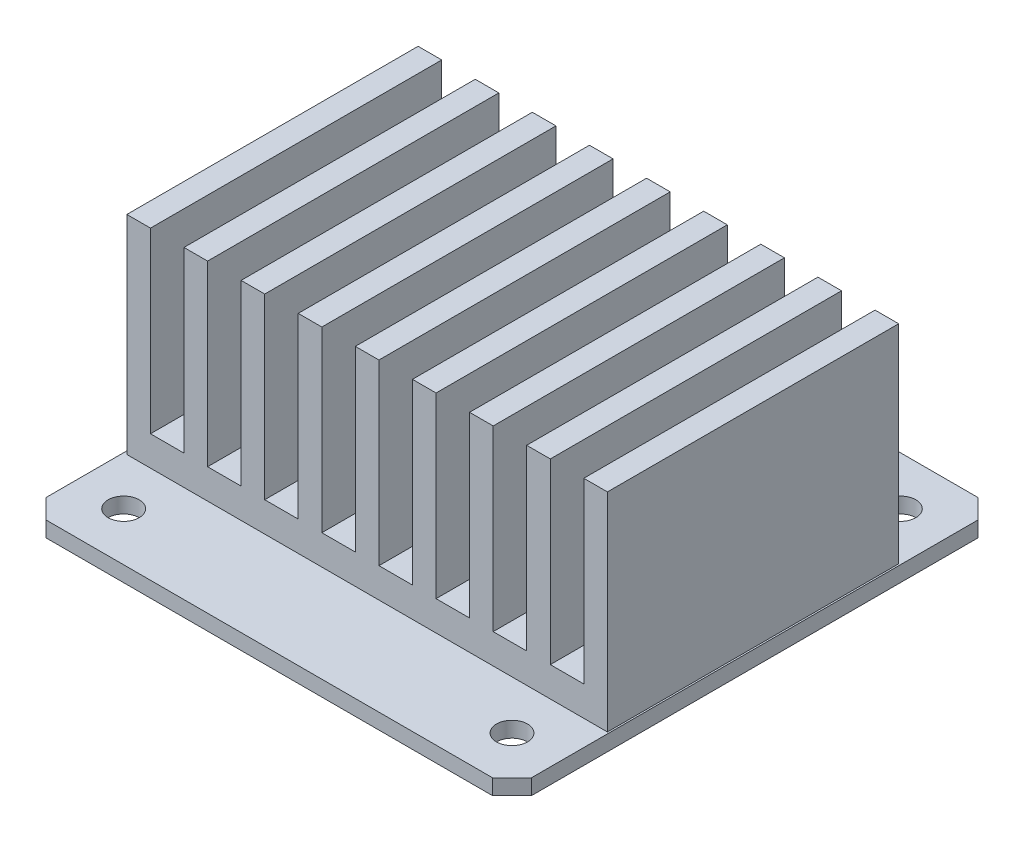
from build123d import *

# Parameters (mm, degrees)
SKETCH1_R                = 1.6
BOSS_EXTRUDE1_DEPTH      = 1.6
BOSS_EXTRUDE2_DEPTH      = 15
BOSS_EXTRUDE2_DEPTH_BACK = 15
SKETCH3_R                = 4.484115481
BOSS_EXTRUDE3_DEPTH      = 15
SKETCH4_W                = 17.802607731
SKETCH4_H                = 6.826563867
BOSS_EXTRUDE4_DEPTH      = 10


with BuildPart() as part:
    # Sketch1 → Boss-Extrude1 (new body)
    with BuildSketch(Plane(origin=(0, 0, 0), x_dir=(1, 0, 0), z_dir=(0, 1, 0))):
        Polygon((-25, 23), (-23, 25), (23, 25), (25, 23), (25, -23), (23, -25), (-23, -25), (-25, -23), align=None)
        with Locations((20, 20)):
            Circle(SKETCH1_R, mode=Mode.SUBTRACT)
        with Locations((-20, 20)):
            Circle(SKETCH1_R, mode=Mode.SUBTRACT)
        with Locations((-20, -20)):
            Circle(SKETCH1_R, mode=Mode.SUBTRACT)
        with Locations((20, -20)):
            Circle(SKETCH1_R, mode=Mode.SUBTRACT)
    extrude(amount=BOSS_EXTRUDE1_DEPTH)

    # Sketch2 → Boss-Extrude2 (add, two sides)
    with BuildSketch(Plane.XY) as boss_extrude2_sk:
        Polygon((-24.671549394, 1.6), (-24.671549394, 23.015646785), (-22.237958156, 23.015646785), (-22.237958156, 4.666777426), (-18.788248299, 4.666777426), (-18.788248299, 23.015646785), (-16.354657061, 23.015646785), (-16.354657061, 4.666777426), (-12.904947204, 4.666777426), (-12.904947204, 23.015646785), (-10.471355966, 23.015646785), (-10.471355966, 4.666777426), (-7.021646108, 4.666777426), (-7.021646108, 23.015646785), (-4.588054871, 23.015646785), (-4.588054871, 4.666777426), (-1.138345013, 4.666777426), (-1.138345013, 23.015646785), (1.295246225, 23.015646785), (1.295246225, 4.666777426), (4.744956082, 4.666777426), (4.744956082, 23.015646785), (7.17854732, 23.015646785), (7.17854732, 4.666777426), (10.628257178, 4.666777426), (10.628257178, 23.015646785), (13.061848415, 23.015646785), (13.061848415, 4.666777426), (16.511558273, 4.666777426), (16.511558273, 23.015646785), (18.945149511, 23.015646785), (18.945149511, 4.666777426), (22.394859368, 4.666777426), (22.394859368, 23.015646785), (24.828450606, 23.015646785), (24.828450606, 1.6), align=None)
    extrude(amount=BOSS_EXTRUDE2_DEPTH)
    extrude(boss_extrude2_sk.sketch, amount=-BOSS_EXTRUDE2_DEPTH_BACK)

    # Sketch3 → Boss-Extrude3 (add)
    with BuildSketch(Plane.XZ):
        with Locations((-12.381512895, -18.471878698)):
            Circle(SKETCH3_R)
    extrude(amount=BOSS_EXTRUDE3_DEPTH)

    # Sketch4 → Boss-Extrude4 (add)
    with BuildSketch(Plane.XZ):
        with Locations((5.421094835, -18.873441279)):
            Rectangle(SKETCH4_W, SKETCH4_H)
    extrude(amount=BOSS_EXTRUDE4_DEPTH)


solid = part.part
